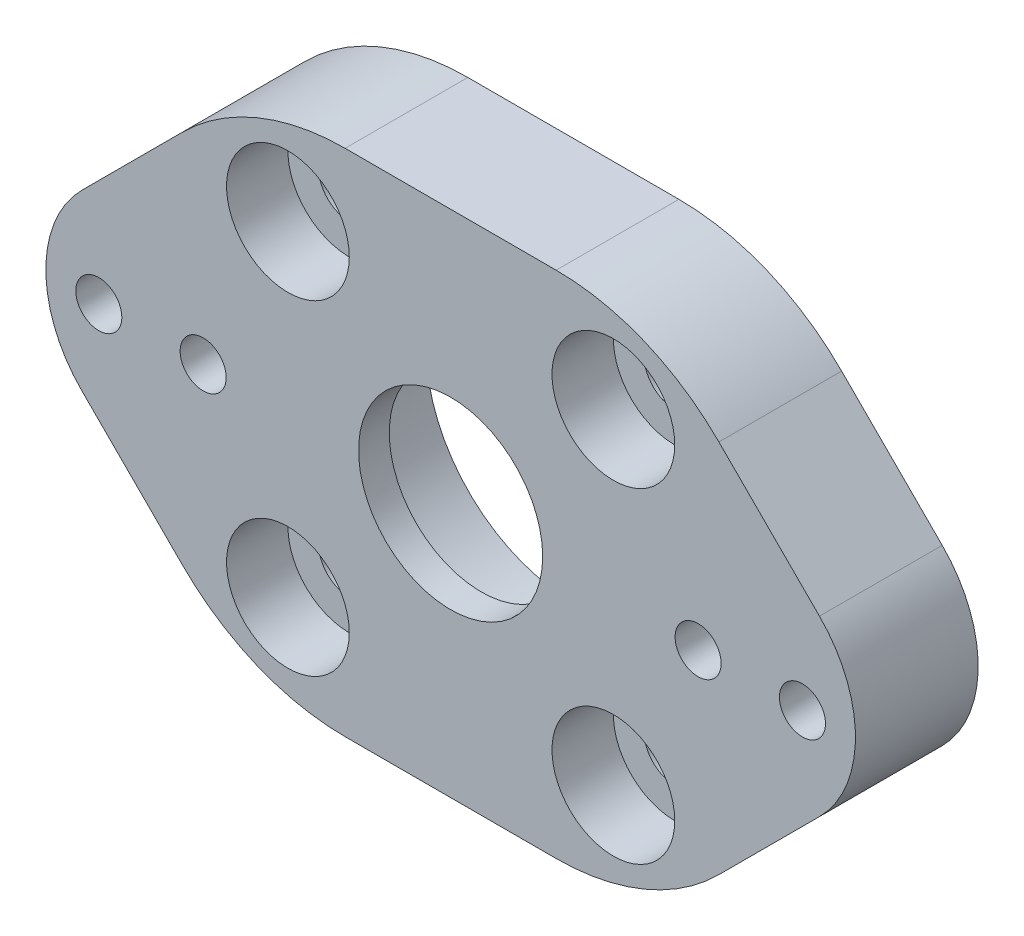
from build123d import *

# Parameters (mm, degrees)
SKETCH1_R           = 2
SKETCH1_R_2         = 9.6
BOSS_EXTRUDE1_DEPTH = 8
SKETCH2_R           = 4
CUT_EXTRUDE1_DEPTH  = 4
SKETCH3_R           = 1.5
CUT_EXTRUDE2_DEPTH  = 10
CUT_EXTRUDE3_DEPTH  = 3
FILLET1_R           = 8
CUT_EXTRUDE4_DEPTH  = 9
FILLET2_R           = 15
SKETCH7_R           = 9.6
SKETCH7_R_2         = 6
BOSS_EXTRUDE2_DEPTH = 2


with BuildPart() as part:
    # Sketch1 → Boss-Extrude1 (new body)
    with BuildSketch(Plane.XY):
        Polygon((-29.69848481, 0), (0, 29.69848481), (29.69848481, 0), (0, -29.69848481), align=None)
        with Locations((10.606601718, 10.606601718)):
            Circle(SKETCH1_R, mode=Mode.SUBTRACT)
        with Locations((10.606601718, -10.606601718)):
            Circle(SKETCH1_R, mode=Mode.SUBTRACT)
        with Locations((-10.606601718, -10.606601718)):
            Circle(SKETCH1_R, mode=Mode.SUBTRACT)
        with Locations((-10.606601718, 10.606601718)):
            Circle(SKETCH1_R, mode=Mode.SUBTRACT)
        Circle(SKETCH1_R_2, mode=Mode.SUBTRACT)
    extrude(amount=BOSS_EXTRUDE1_DEPTH)

    # Sketch2 → Cut-Extrude1 (cut)
    with BuildSketch(Plane.XY.offset(8)):
        with Locations((-10.606601718, 10.606601718)):
            Circle(SKETCH2_R)
        with Locations((10.606601718, 10.606601718)):
            Circle(SKETCH2_R)
        with Locations((10.606601718, -10.606601718)):
            Circle(SKETCH2_R)
        with Locations((-10.606601718, -10.606601718)):
            Circle(SKETCH2_R)
    extrude(amount=-CUT_EXTRUDE1_DEPTH, mode=Mode.SUBTRACT)

    # Sketch3 → Cut-Extrude2 (cut)
    with BuildSketch(Plane.XY.offset(8)):
        with Locations((-22.931196288, -0.213718328)):
            Circle(SKETCH3_R)
        with Locations((-16.131196288, -0.213718328)):
            Circle(SKETCH3_R)
        with Locations((16.131196288, -0.216214782)):
            Circle(SKETCH3_R)
        with Locations((22.931196288, -0.216214782)):
            Circle(SKETCH3_R)
    extrude(amount=-CUT_EXTRUDE2_DEPTH, mode=Mode.SUBTRACT)

    # Sketch4 → Cut-Extrude3 (cut)
    with BuildSketch(Plane(origin=(0, 0, 0), x_dir=(-1, 0, 0), z_dir=(0, 0, -1))):
        Polygon((-24.446740745, 2.408785218), (-25.962285202, -0.216214782), (-24.446740745, -2.841214782), (-21.415651832, -2.841214782), (-19.900107375, -0.216214782), (-21.415651832, 2.408785218), align=None)
        Polygon((-13.506196288, 1.299329674), (-16.131196288, 2.814874131), (-18.756196288, 1.299329674), (-18.756196288, -1.731759239), (-16.131196288, -3.247303696), (-13.506196288, -1.731759239), align=None)
        Polygon((18.756196288, 1.301826129), (16.131196288, 2.817370585), (13.506196288, 1.301826129), (13.506196288, -1.729262785), (16.131196288, -3.244807241), (18.756196288, -1.729262785), align=None)
        Polygon((21.415651832, 2.411281672), (19.900107375, -0.213718328), (21.415651832, -2.838718328), (24.446740745, -2.838718328), (25.962285202, -0.213718328), (24.446740745, 2.411281672), align=None)
    extrude(amount=-CUT_EXTRUDE3_DEPTH, mode=Mode.SUBTRACT)

    # Fillet1
    fillet1_edges = [part.edges().sort_by_distance(p)[0] for p in [
        (-29.69848481, 0, 4),
        (29.69848481, 0, 4),
    ]]
    fillet(fillet1_edges, radius=FILLET1_R)

    # Sketch5 → Cut-Extrude4 (cut, through all)
    with BuildSketch(Plane.XY.offset(8)):
        Polygon((13.091883092, 16.606601718), (0, 29.69848481), (-13.091883092, 16.606601718), align=None)
        Polygon((-13.091883092, -16.606601718), (0, -29.69848481), (13.091883092, -16.606601718), align=None)
    extrude(amount=-CUT_EXTRUDE4_DEPTH, mode=Mode.SUBTRACT)

    # Fillet2
    fillet2_edges = [part.edges().sort_by_distance(p)[0] for p in [
        (13.091883092, 16.606601718, 4),
        (-13.091883092, 16.606601718, 4),
        (-13.091883092, -16.606601718, 4),
        (13.091883092, -16.606601718, 4),
    ]]
    fillet(fillet2_edges, radius=FILLET2_R)

    # Sketch7 → Boss-Extrude2 (add)
    with BuildSketch(Plane.XY.offset(8)):
        Circle(SKETCH7_R)
        Circle(SKETCH7_R_2, mode=Mode.SUBTRACT)
    extrude(amount=-BOSS_EXTRUDE2_DEPTH)


solid = part.part
